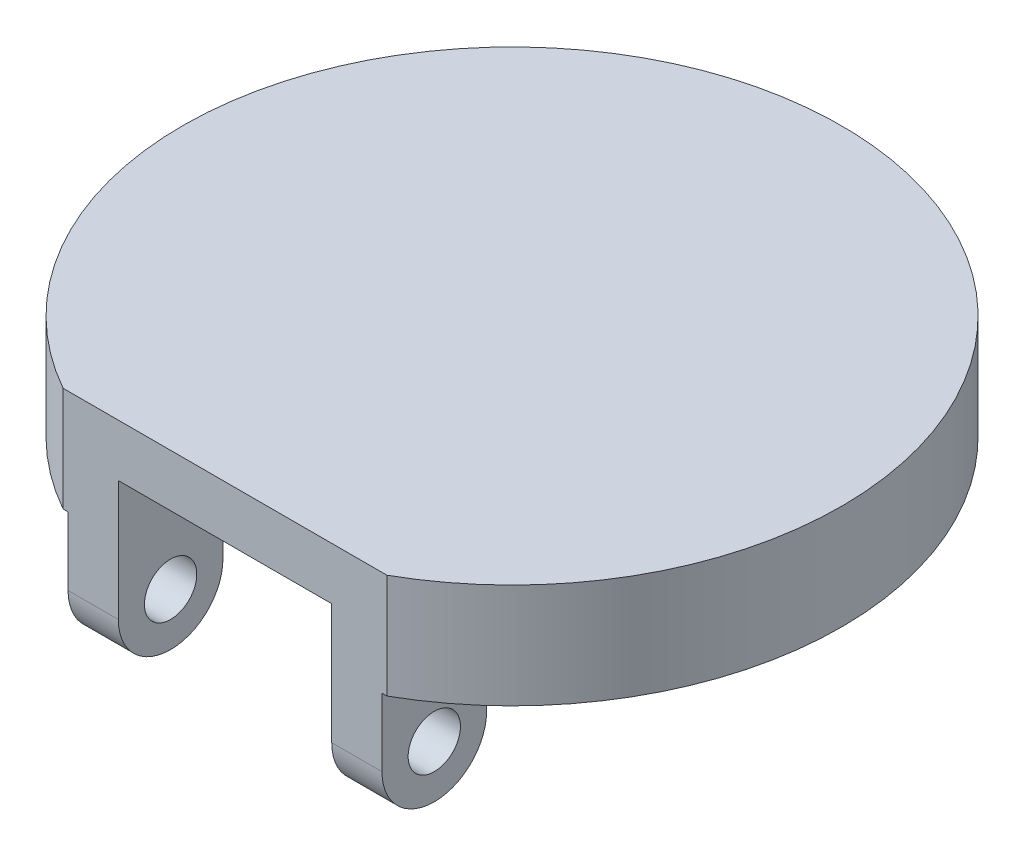
from build123d import *

# Parameters (mm, degrees)
SKETCH1_R               = 20.000000005
BOSS_EXTRUDE1_DEPTH     = 6.35
BOSS_EXTRUDE2_DEPTH     = 3.175
SKETCH3_R               = 1.5875
CUT_EXTRUDE1_DEPTH      = 30.525000005
CUT_EXTRUDE2_DEPTH      = 3.175
SKETCH6_W               = 9.069473667
SKETCH6_H               = 11.755238044
CUT_EXTRUDE3_DEPTH      = 14.650000005
CUT_EXTRUDE3_DEPTH_BACK = 27.350000005
CUT_EXTRUDE4_DEPTH      = 6.477
CUT_EXTRUDE4_DEPTH_BACK = 6.477


with BuildPart() as part:
    # Sketch1 → Boss-Extrude1 (new body)
    with BuildSketch(Plane(origin=(0, 0, 0), x_dir=(1, 0, 0), z_dir=(0, 1, 0))):
        Circle(SKETCH1_R)
    extrude(amount=BOSS_EXTRUDE1_DEPTH)

    # Sketch2 → Boss-Extrude2 (add)
    with BuildSketch(Plane(origin=(6.35, 0, 0), x_dir=(0, 0, -1), z_dir=(1, 0, 0))):
        with BuildLine():
            Line((-17.420082718, 0), (-17.420082718, -4.127))
            ThreePointArc((-17.420082718, -4.127), (-14.245082718, -7.302), (-11.070082718, -4.127))
            Line((-11.070082718, -4.127), (-11.070082718, -3.175))
            ThreePointArc((-11.070082718, -3.175), (-10.140146748, -0.92993597), (-7.895082718, 0))
            Line((-7.895082718, 0), (-5.849160659, 0))
            Line((-5.849160659, 0), (-5.849160659, 6.35))
            Line((-5.849160659, 6.35), (-11.070082718, 6.35))
            ThreePointArc((-11.070082718, 6.35), (-15.560210778, 4.490128061), (-17.420082718, 0))
        make_face()
    boss_extrude2 = extrude(amount=BOSS_EXTRUDE2_DEPTH)

    # Mirror1: Boss-Extrude2 across plane
    add(boss_extrude2.mirror(Plane(origin=(0, 0, 0), x_dir=(0, 0, 1), z_dir=(1, 0, 0))))

    # Sketch3 → Cut-Extrude1 (cut, through all)
    with BuildSketch(Plane(origin=(9.525, 0, 0), x_dir=(0, 0, -1), z_dir=(1, 0, 0))):
        with Locations((-14.245082718, -4.127)):
            Circle(SKETCH3_R)
    extrude(amount=-CUT_EXTRUDE1_DEPTH, mode=Mode.SUBTRACT)

    # Sketch5 → Cut-Extrude2 (cut)
    with BuildSketch(Plane.XZ):
        with BuildLine():
            Line((6.35, 18.965165441), (6.35, 7.605609073))
            ThreePointArc((6.35, 7.605609073), (0, -9.907965955), (-6.35, 7.605609073))
            Line((-6.35, 7.605609073), (-6.35, 18.965165441))
            ThreePointArc((-6.35, 18.965165441), (0, 20.000000005), (6.35, 18.965165441))
        make_face()
    extrude(amount=-CUT_EXTRUDE2_DEPTH, mode=Mode.SUBTRACT)

    # Sketch6 → Cut-Extrude3 (cut, two sides)
    with BuildSketch(Plane(origin=(6.35, 0, 0), x_dir=(0, 0, -1), z_dir=(1, 0, 0))) as cut_extrude3_sk:
        with Locations((-21.954819552, 5.877619022)):
            Rectangle(SKETCH6_W, SKETCH6_H)
    extrude(amount=CUT_EXTRUDE3_DEPTH, mode=Mode.SUBTRACT)
    extrude(cut_extrude3_sk.sketch, amount=-CUT_EXTRUDE3_DEPTH_BACK, mode=Mode.SUBTRACT)

    # Sketch7 → Cut-Extrude4 (cut, two sides)
    with BuildSketch(Plane(origin=(0, 0, 0), x_dir=(0, 0, -1), z_dir=(1, 0, 0))) as cut_extrude4_sk:
        with BuildLine():
            Line((-6.646914412, 0), (-6.646914412, 3.175))
            Line((-6.646914412, 3.175), (-7.605609073, 3.175))
            Line((-7.605609073, 3.175), (-17.420082718, 3.175))
            Line((-17.420082718, 3.175), (-17.420082718, -4.127))
            ThreePointArc((-17.420082718, -4.127), (-14.245082718, -7.302), (-11.070082718, -4.127))
            Line((-11.070082718, -4.127), (-11.070082718, -3.175))
            ThreePointArc((-11.070082718, -3.175), (-10.140146748, -0.92993597), (-7.895082718, 0))
            Line((-7.895082718, 0), (-6.646914412, 0))
        make_face()
    extrude(amount=CUT_EXTRUDE4_DEPTH, mode=Mode.SUBTRACT)
    extrude(cut_extrude4_sk.sketch, amount=-CUT_EXTRUDE4_DEPTH_BACK, mode=Mode.SUBTRACT)


solid = part.part
